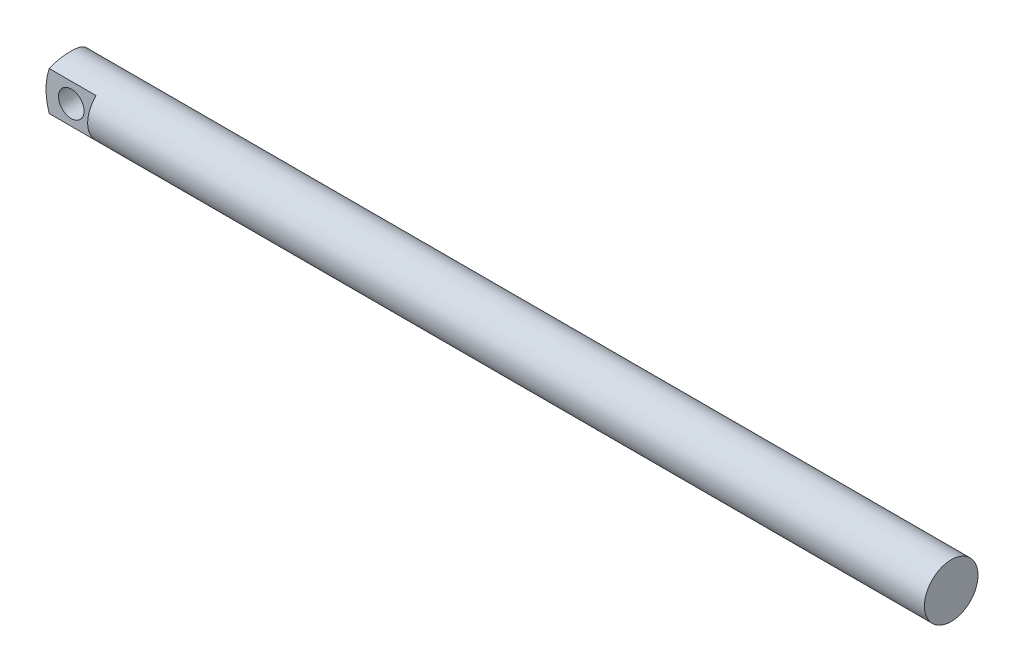
from build123d import *

# Parameters (mm, degrees)
BOSS_EXTRUDE1_DEPTH = 4.5
SKETCH1_3_R         = 2.125
BOSS_EXTRUDE2_DEPTH = 3
CUT_EXTRUDE1_DEPTH  = 200
CUT_EXTRUDE4_DEPTH  = 200
CUT_EXTRUDE5_DEPTH  = 200
CUT_EXTRUDE6_DEPTH  = 200
CUT_EXTRUDE8_DEPTH  = 361


with BuildPart() as part:
    # Sketch1 → Boss-Extrude1 (new, symmetric)
    with BuildSketch(Plane.XY):
        Polygon((139, 8.9), (0, 8.9), (0, 4.45), (0, 0), (139, 0), align=None)
    extrude(amount=BOSS_EXTRUDE1_DEPTH, both=True)

    # Sketch1_3 → Boss-Extrude2 (add, symmetric)
    with BuildSketch(Plane.XY):
        with BuildLine():
            Line((0, 4.45), (0, 8.9))
            Line((0, 8.9), (0, 9.4))
            Line((0, 9.4), (-7.008929738, 9.4))
            ThreePointArc((-7.008929738, 9.4), (-8.32, 4.45), (-7.008929738, -0.5))
            Line((-7.008929738, -0.5), (0, -0.5))
            Line((0, -0.5), (0, 0))
            Line((0, 0), (0, 4.45))
        make_face()
        with Locations((-4.125, 4.45)):
            Circle(SKETCH1_3_R, mode=Mode.SUBTRACT)
    extrude(amount=BOSS_EXTRUDE2_DEPTH, both=True)

    # Sketch2 → Cut-Extrude1 (cut, symmetric)
    with BuildSketch(Plane(origin=(139, 0, 0), x_dir=(0, 0, -1), z_dir=(1, 0, 0))):
        with BuildLine():
            ThreePointArc((0.05, 8.9), (3.196625176, 7.596625176), (4.5, 4.45))
            Line((4.5, 4.45), (4.5, 8.9))
            Line((4.5, 8.9), (0.05, 8.9))
        make_face()
        with BuildLine():
            Line((4.5, 0), (4.5, 4.45))
            ThreePointArc((4.5, 4.45), (3.196625176, 1.303374824), (0.05, 0))
            Line((0.05, 0), (4.5, 0))
        make_face()
        with BuildLine():
            Line((-4.5, 0), (0.05, 0))
            ThreePointArc((0.05, 0), (-3.096625176, 1.303374824), (-4.4, 4.45))
            Line((-4.4, 4.45), (-4.5, 0))
        make_face()
        with BuildLine():
            ThreePointArc((-4.4, 4.45), (-3.096625176, 7.596625176), (0.05, 8.9))
            Line((0.05, 8.9), (-4.4, 8.9))
            Line((-4.4, 8.9), (-4.4, 4.45))
        make_face()
    extrude(amount=CUT_EXTRUDE1_DEPTH, both=True, mode=Mode.SUBTRACT)


with BuildPart() as cut_extrude1_piece_1:
    # of the separate pieces the step leaves, piece 1, a body of its own (cut_extrude1_pieces)
    add(part.part.solids().sort_by_distance((139, 8.9, -0.05))[0])


with BuildPart() as cut_extrude1_piece_2:
    # of the separate pieces the step leaves, piece 2, a body of its own (cut_extrude1_pieces)
    add(part.part.solids().sort_by_distance((139, 8.9, 4.5))[0])

    # Sketch8 → Cut-Extrude8 (cut, symmetric)
    with BuildSketch(Plane(origin=(139, 0, 0), x_dir=(0, 0, -1), z_dir=(1, 0, 0))):
        Polygon((-4.4, 4.45), (-4.497226285, 0.123430317), (-4.497226285, -0.993132251), (-5.525689044, -1.409682141), (-10.667797883, 2.280439271), (-5.525689044, 10.659843857), (-2.697341369, 11.337001628), (-4.4, 7.708140942), align=None)
    extrude(amount=CUT_EXTRUDE8_DEPTH, both=True, mode=Mode.SUBTRACT)


with BuildPart() as cut_extrude1_piece_3:
    # of the separate pieces the step leaves, piece 3, a body of its own (cut_extrude1_pieces)
    add(part.part.solids().sort_by_distance((0, 0, 3))[0])

    # Sketch6 → Cut-Extrude5 (cut, symmetric)
    with BuildSketch(Plane.XY.offset(3)):
        Polygon((0, 0), (0.715891122, -1.192951857), (-7.933711104, -1.400818057), (-7.27530569, 0), align=None)
    extrude(amount=CUT_EXTRUDE5_DEPTH, both=True, mode=Mode.SUBTRACT)


with BuildPart() as cut_extrude1_piece_4:
    # of the separate pieces the step leaves, piece 4, a body of its own (cut_extrude1_pieces)
    add(part.part.solids().sort_by_distance((0, 8.9, -3))[0])

    # Sketch5 → Cut-Extrude4 (cut, symmetric)
    with BuildSketch(Plane(origin=(0, 0, -3), x_dir=(-1, 0, 0), z_dir=(0, 0, -1))):
        Polygon((7.27530569, 8.9), (0, 8.9), (-1.536483872, 9.442626596), (6.771268728, 9.782768914), align=None)
    extrude(amount=CUT_EXTRUDE4_DEPTH, both=True, mode=Mode.SUBTRACT)

    # Sketch7 → Cut-Extrude6 (cut, symmetric)
    with BuildSketch(Plane.XY.offset(3)):
        Polygon((-7.27530569, 8.9), (-6.80653665, 9.625984501), (-7.207484275, 9.625984501), align=None)
    extrude(amount=CUT_EXTRUDE6_DEPTH, both=True, mode=Mode.SUBTRACT)


solid = cut_extrude1_piece_1.part
